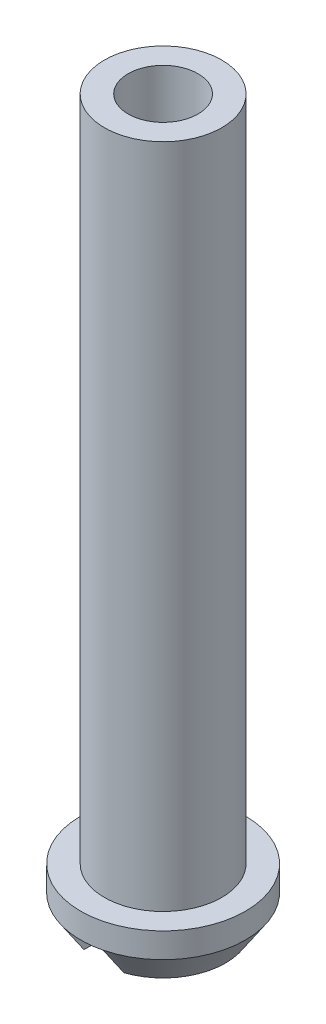
from build123d import *

# Parameters (mm, degrees)
CHAMFER2_SIZE           = 1.778
CHAMFER2_SIZE2          = 2.54
SKETCH2_W               = 4.064
SKETCH2_H               = 3.048
CUT_EXTRUDE1_DEPTH      = 9.382
CUT_EXTRUDE1_DEPTH_BACK = 9.382
CUT_EXTRUDE2_DEPTH      = 9.382
CUT_EXTRUDE2_DEPTH_BACK = 9.382


with BuildPart() as part:
    # Sketch1 → Base-Revolve (revolve)
    with BuildSketch(Plane.XY):
        Polygon((3.556, 73.406), (3.556, 0), (6.35, 0), (8.382, 3.048), (8.382, 5.588), (5.969, 5.588), (5.969, 73.406), align=None)
    revolve(axis=Axis((0, 0, 0), (0, 1, 0)))

    # Chamfer2
    chamfer2_edges = [part.edges().sort_by_distance(p)[0] for p in [
        (-3.556, 0, 0),
    ]]
    chamfer2_side = [part.faces().sort_by_distance(p)[0] for p in [
        (-3.735605122, 0, 0),
    ]]
    chamfer(chamfer2_edges, length=CHAMFER2_SIZE, length2=CHAMFER2_SIZE2, reference=chamfer2_side[0])

    # Sketch2 → Cut-Extrude1 (cut, two sides)
    with BuildSketch(Plane.XY) as cut_extrude1_sk:
        with Locations((0, 1.524)):
            Rectangle(SKETCH2_W, SKETCH2_H)
    extrude(amount=CUT_EXTRUDE1_DEPTH, mode=Mode.SUBTRACT)
    extrude(cut_extrude1_sk.sketch, amount=-CUT_EXTRUDE1_DEPTH_BACK, mode=Mode.SUBTRACT)

    # Sketch3 → Cut-Extrude2 (cut, two sides)
    with BuildSketch(Plane.XY) as cut_extrude2_sk:
        Polygon((-7.874, 5.08), (-7.874, 2.286), (-8.382, 3.048), (-8.382, 5.08), align=None)
    extrude(amount=CUT_EXTRUDE2_DEPTH, mode=Mode.SUBTRACT)
    extrude(cut_extrude2_sk.sketch, amount=-CUT_EXTRUDE2_DEPTH_BACK, mode=Mode.SUBTRACT)


solid = part.part
